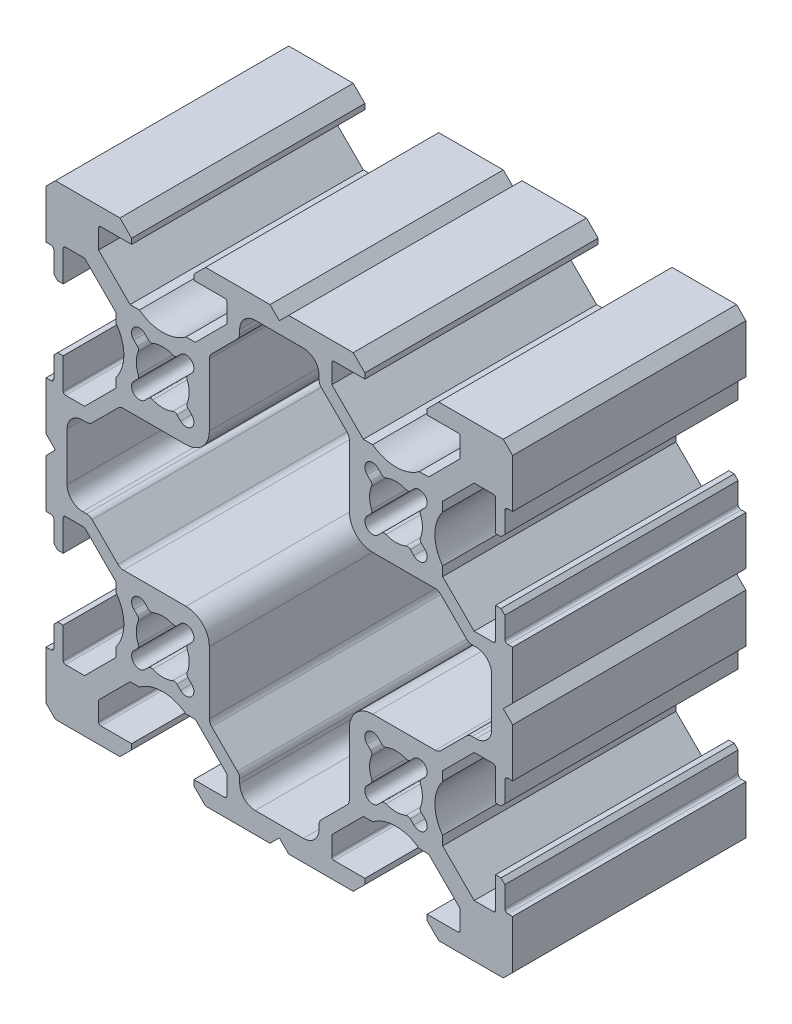
from build123d import *

# Parameters (mm, degrees)
EXTRUDE_1_DEPTH = 30


with BuildPart() as part:
    # Эскиз1 → Бобышка-Вытянуть1 (new body)
    with BuildSketch(Plane.XY):
        with BuildLine():
            Line((26.437609342, 19), (27.137609342, 19))
            Line((27.137609342, 19), (27.637609342, 19.5))
            Line((27.637609342, 19.5), (27.637609342, 22.15))
            ThreePointArc((27.637609342, 22.15), (27.75476663, 22.432842712), (28.037609342, 22.55))
            Line((28.037609342, 22.55), (28.637609342, 22.55))
            Line((28.637609342, 22.55), (28.637609342, 28.8))
            Line((28.637609342, 28.8), (27.437609342, 30))
            Line((27.437609342, 30), (19.137609342, 30))
            Line((19.137609342, 30), (17.637609342, 28.5))
            Line((17.637609342, 28.5), (17.637609342, 27.8))
            Line((17.637609342, 27.8), (21.587609342, 27.8))
            ThreePointArc((21.587609342, 27.8), (21.799741377, 27.712132034), (21.887609342, 27.5))
            Line((21.887609342, 27.5), (21.887609342, 25.05312252))
            Line((21.887609342, 25.05312252), (17.834486822, 21))
            Line((17.834486822, 21), (16.637609342, 21))
            ThreePointArc((16.637609342, 21), (13.637609342, 20), (10.637609342, 21))
            Line((10.637609342, 21), (9.440731863, 21))
            Line((9.440731863, 21), (5.387609342, 25.05312252))
            Line((5.387609342, 25.05312252), (5.387609342, 27.5))
            ThreePointArc((5.387609342, 27.5), (5.475477308, 27.712132034), (5.687609342, 27.8))
            Line((5.687609342, 27.8), (9.637609342, 27.8))
            Line((9.637609342, 27.8), (9.637609342, 28.5))
            Line((9.637609342, 28.5), (8.137609342, 30))
            Line((8.137609342, 30), (-0.162390658, 30))
            Line((-0.162390658, 30), (-1.362390658, 28.8))
            Line((-1.362390658, 28.8), (-2.562390658, 30))
            Line((-2.562390658, 30), (-10.862390658, 30))
            Line((-10.862390658, 30), (-12.362390658, 28.5))
            Line((-12.362390658, 28.5), (-12.362390658, 27.8))
            Line((-12.362390658, 27.8), (-8.412390658, 27.8))
            ThreePointArc((-8.412390658, 27.8), (-8.200258623, 27.712132034), (-8.112390658, 27.5))
            Line((-8.112390658, 27.5), (-8.112390658, 25.05312252))
            Line((-8.112390658, 25.05312252), (-12.165513178, 21))
            Line((-12.165513178, 21), (-13.362390658, 21))
            ThreePointArc((-13.362390658, 21), (-16.362390658, 20), (-19.362390658, 21))
            Line((-19.362390658, 21), (-20.559268137, 21))
            Line((-20.559268137, 21), (-24.612390658, 25.05312252))
            Line((-24.612390658, 25.05312252), (-24.612390658, 27.5))
            ThreePointArc((-24.612390658, 27.5), (-24.524522692, 27.712132034), (-24.312390658, 27.8))
            Line((-24.312390658, 27.8), (-20.362390658, 27.8))
            Line((-20.362390658, 27.8), (-20.362390658, 28.5))
            Line((-20.362390658, 28.5), (-21.862390658, 30))
            Line((-21.862390658, 30), (-30.162390658, 30))
            Line((-30.162390658, 30), (-31.362390658, 28.8))
            Line((-31.362390658, 28.8), (-31.362390658, 22.55))
            Line((-31.362390658, 22.55), (-30.762390658, 22.55))
            ThreePointArc((-30.762390658, 22.55), (-30.479547945, 22.432842712), (-30.362390658, 22.15))
            Line((-30.362390658, 22.15), (-30.362390658, 19.5))
            Line((-30.362390658, 19.5), (-29.862390658, 19))
            Line((-29.862390658, 19), (-29.162390658, 19))
            Line((-29.162390658, 19), (-29.162390658, 22.95))
            ThreePointArc((-29.162390658, 22.95), (-29.074522692, 23.162132034), (-28.862390658, 23.25))
            Line((-28.862390658, 23.25), (-26.415513178, 23.25))
            Line((-26.415513178, 23.25), (-22.362390658, 19.19687748))
            Line((-22.362390658, 19.19687748), (-22.362390658, 18))
            ThreePointArc((-22.362390658, 18), (-21.362390658, 15), (-22.362390658, 12))
            Line((-22.362390658, 12), (-22.362390658, 10.80312252))
            Line((-22.362390658, 10.80312252), (-26.415513178, 6.75))
            Line((-26.415513178, 6.75), (-28.862390658, 6.75))
            ThreePointArc((-28.862390658, 6.75), (-29.074522692, 6.837867966), (-29.162390658, 7.05))
            Line((-29.162390658, 7.05), (-29.162390658, 11))
            Line((-29.162390658, 11), (-29.862390658, 11))
            Line((-29.862390658, 11), (-30.362390658, 10.5))
            Line((-30.362390658, 10.5), (-30.362390658, 7.85))
            ThreePointArc((-30.362390658, 7.85), (-30.479547945, 7.567157288), (-30.762390658, 7.45))
            Line((-30.762390658, 7.45), (-31.362390658, 7.45))
            Line((-31.362390658, 7.45), (-31.362390658, 1.2))
            Line((-31.362390658, 1.2), (-30.162390658, 0))
            Line((-30.162390658, 0), (-31.362390658, -1.2))
            Line((-31.362390658, -1.2), (-31.362390658, -7.45))
            Line((-31.362390658, -7.45), (-30.762390658, -7.45))
            ThreePointArc((-30.762390658, -7.45), (-30.479547945, -7.567157288), (-30.362390658, -7.85))
            Line((-30.362390658, -7.85), (-30.362390658, -10.5))
            Line((-30.362390658, -10.5), (-29.862390658, -11))
            Line((-29.862390658, -11), (-29.162390658, -11))
            Line((-29.162390658, -11), (-29.162390658, -7.05))
            ThreePointArc((-29.162390658, -7.05), (-29.074522692, -6.837867966), (-28.862390658, -6.75))
            Line((-28.862390658, -6.75), (-26.415513178, -6.75))
            Line((-26.415513178, -6.75), (-22.362390658, -10.80312252))
            Line((-22.362390658, -10.80312252), (-22.362390658, -12))
            ThreePointArc((-22.362390658, -12), (-21.362390658, -15), (-22.362390658, -18))
            Line((-22.362390658, -18), (-22.362390658, -19.19687748))
            Line((-22.362390658, -19.19687748), (-26.415513178, -23.25))
            Line((-26.415513178, -23.25), (-28.862390658, -23.25))
            ThreePointArc((-28.862390658, -23.25), (-29.074522692, -23.162132034), (-29.162390658, -22.95))
            Line((-29.162390658, -22.95), (-29.162390658, -19))
            Line((-29.162390658, -19), (-29.862390658, -19))
            Line((-29.862390658, -19), (-30.362390658, -19.5))
            Line((-30.362390658, -19.5), (-30.362390658, -22.15))
            ThreePointArc((-30.362390658, -22.15), (-30.479547945, -22.432842712), (-30.762390658, -22.55))
            Line((-30.762390658, -22.55), (-31.362390658, -22.55))
            Line((-31.362390658, -22.55), (-31.362390658, -28.8))
            Line((-31.362390658, -28.8), (-30.162390658, -30))
            Line((-30.162390658, -30), (-21.862390658, -30))
            Line((-21.862390658, -30), (-20.362390658, -28.5))
            Line((-20.362390658, -28.5), (-20.362390658, -27.8))
            Line((-20.362390658, -27.8), (-24.312390658, -27.8))
            ThreePointArc((-24.312390658, -27.8), (-24.524522692, -27.712132034), (-24.612390658, -27.5))
            Line((-24.612390658, -27.5), (-24.612390658, -25.05312252))
            Line((-24.612390658, -25.05312252), (-20.559268137, -21))
            Line((-20.559268137, -21), (-19.362390658, -21))
            ThreePointArc((-19.362390658, -21), (-16.362390658, -20), (-13.362390658, -21))
            Line((-13.362390658, -21), (-12.165513178, -21))
            Line((-12.165513178, -21), (-8.112390658, -25.05312252))
            Line((-8.112390658, -25.05312252), (-8.112390658, -27.5))
            ThreePointArc((-8.112390658, -27.5), (-8.200258623, -27.712132034), (-8.412390658, -27.8))
            Line((-8.412390658, -27.8), (-12.362390658, -27.8))
            Line((-12.362390658, -27.8), (-12.362390658, -28.5))
            Line((-12.362390658, -28.5), (-10.862390658, -30))
            Line((-10.862390658, -30), (-2.562390658, -30))
            Line((-2.562390658, -30), (-1.362390658, -28.8))
            Line((-1.362390658, -28.8), (-0.162390658, -30))
            Line((-0.162390658, -30), (8.137609342, -30))
            Line((8.137609342, -30), (9.637609342, -28.5))
            Line((9.637609342, -28.5), (9.637609342, -27.8))
            Line((9.637609342, -27.8), (5.687609342, -27.8))
            ThreePointArc((5.687609342, -27.8), (5.475477308, -27.712132034), (5.387609342, -27.5))
            Line((5.387609342, -27.5), (5.387609342, -25.05312252))
            Line((5.387609342, -25.05312252), (9.440731863, -21))
            Line((9.440731863, -21), (10.637609342, -21))
            ThreePointArc((10.637609342, -21), (13.637609342, -20), (16.637609342, -21))
            Line((16.637609342, -21), (17.834486822, -21))
            Line((17.834486822, -21), (21.887609342, -25.05312252))
            Line((21.887609342, -25.05312252), (21.887609342, -27.5))
            ThreePointArc((21.887609342, -27.5), (21.799741377, -27.712132034), (21.587609342, -27.8))
            Line((21.587609342, -27.8), (17.637609342, -27.8))
            Line((17.637609342, -27.8), (17.637609342, -28.5))
            Line((17.637609342, -28.5), (19.137609342, -30))
            Line((19.137609342, -30), (27.437609342, -30))
            Line((27.437609342, -30), (28.637609342, -28.8))
            Line((28.637609342, -28.8), (28.637609342, -22.55))
            Line((28.637609342, -22.55), (28.037609342, -22.55))
            ThreePointArc((28.037609342, -22.55), (27.75476663, -22.432842712), (27.637609342, -22.15))
            Line((27.637609342, -22.15), (27.637609342, -19.5))
            Line((27.637609342, -19.5), (27.137609342, -19))
            Line((27.137609342, -19), (26.437609342, -19))
            Line((26.437609342, -19), (26.437609342, -22.95))
            ThreePointArc((26.437609342, -22.95), (26.349741377, -23.162132034), (26.137609342, -23.25))
            Line((26.137609342, -23.25), (23.690731863, -23.25))
            Line((23.690731863, -23.25), (19.637609342, -19.19687748))
            Line((19.637609342, -19.19687748), (19.637609342, -18))
            ThreePointArc((19.637609342, -18), (18.637609342, -15), (19.637609342, -12))
            Line((19.637609342, -12), (19.637609342, -10.80312252))
            Line((19.637609342, -10.80312252), (23.690731863, -6.75))
            Line((23.690731863, -6.75), (26.137609342, -6.75))
            ThreePointArc((26.137609342, -6.75), (26.349741377, -6.837867966), (26.437609342, -7.05))
            Line((26.437609342, -7.05), (26.437609342, -11))
            Line((26.437609342, -11), (27.137609342, -11))
            Line((27.137609342, -11), (27.637609342, -10.5))
            Line((27.637609342, -10.5), (27.637609342, -7.85))
            ThreePointArc((27.637609342, -7.85), (27.75476663, -7.567157288), (28.037609342, -7.45))
            Line((28.037609342, -7.45), (28.637609342, -7.45))
            Line((28.637609342, -7.45), (28.637609342, -1.2))
            Line((28.637609342, -1.2), (27.437609342, 0))
            Line((27.437609342, 0), (28.637609342, 1.2))
            Line((28.637609342, 1.2), (28.637609342, 7.45))
            Line((28.637609342, 7.45), (28.037609342, 7.45))
            ThreePointArc((28.037609342, 7.45), (27.75476663, 7.567157288), (27.637609342, 7.85))
            Line((27.637609342, 7.85), (27.637609342, 10.5))
            Line((27.637609342, 10.5), (27.137609342, 11))
            Line((27.137609342, 11), (26.437609342, 11))
            Line((26.437609342, 11), (26.437609342, 7.05))
            ThreePointArc((26.437609342, 7.05), (26.349741377, 6.837867966), (26.137609342, 6.75))
            Line((26.137609342, 6.75), (23.690731863, 6.75))
            Line((23.690731863, 6.75), (19.637609342, 10.80312252))
            Line((19.637609342, 10.80312252), (19.637609342, 12))
            ThreePointArc((19.637609342, 12), (18.637609342, 15), (19.637609342, 18))
            Line((19.637609342, 18), (19.637609342, 19.19687748))
            Line((19.637609342, 19.19687748), (23.690731863, 23.25))
            Line((23.690731863, 23.25), (26.137609342, 23.25))
            ThreePointArc((26.137609342, 23.25), (26.349741377, 23.162132034), (26.437609342, 22.95))
            Line((26.437609342, 22.95), (26.437609342, 19))
        make_face()
        with BuildLine():
            Line((-19.615081851, -16.838477631), (-20.074701259, -17.298097039))
            ThreePointArc((-20.074701259, -17.298097039), (-20.074701259, -18.712310601), (-18.660487697, -18.712310601))
            Line((-18.660487697, -18.712310601), (-18.200868289, -18.252691193))
            ThreePointArc((-18.200868289, -18.252691193), (-17.945372966, -18.115954246), (-17.656939996, -18.143905535))
            ThreePointArc((-17.656939996, -18.143905535), (-16.362390658, -18.4), (-15.06784132, -18.143905535))
            ThreePointArc((-15.06784132, -18.143905535), (-14.77940835, -18.115954246), (-14.523913027, -18.252691193))
            Line((-14.523913027, -18.252691193), (-14.064293619, -18.712310601))
            ThreePointArc((-14.064293619, -18.712310601), (-12.650080057, -18.712310601), (-12.650080057, -17.298097039))
            Line((-12.650080057, -17.298097039), (-13.109699464, -16.838477631))
            ThreePointArc((-13.109699464, -16.838477631), (-13.246436412, -16.582982308), (-13.218485123, -16.294549338))
            ThreePointArc((-13.218485123, -16.294549338), (-12.962390658, -15), (-13.218485123, -13.705450662))
            ThreePointArc((-13.218485123, -13.705450662), (-13.246436412, -13.417017692), (-13.109699464, -13.161522369))
            Line((-13.109699464, -13.161522369), (-12.650080057, -12.701902961))
            ThreePointArc((-12.650080057, -12.701902961), (-12.650080057, -11.287689399), (-14.064293619, -11.287689399))
            Line((-14.064293619, -11.287689399), (-14.523913027, -11.747308806))
            ThreePointArc((-14.523913027, -11.747308806), (-14.77940835, -11.884045754), (-15.06784132, -11.856094465))
            ThreePointArc((-15.06784132, -11.856094465), (-16.362390658, -11.6), (-17.656939996, -11.856094465))
            ThreePointArc((-17.656939996, -11.856094465), (-17.945372966, -11.884045754), (-18.200868289, -11.747308807))
            Line((-18.200868289, -11.747308807), (-18.660487697, -11.287689399))
            ThreePointArc((-18.660487697, -11.287689399), (-20.074701259, -11.287689399), (-20.074701259, -12.701902961))
            Line((-20.074701259, -12.701902961), (-19.615081851, -13.161522369))
            ThreePointArc((-19.615081851, -13.161522369), (-19.478344904, -13.417017692), (-19.506296193, -13.705450662))
            ThreePointArc((-19.506296193, -13.705450662), (-19.762390658, -15), (-19.506296193, -16.294549338))
            ThreePointArc((-19.506296193, -16.294549338), (-19.478344904, -16.582982308), (-19.615081851, -16.838477631))
        make_face(mode=Mode.SUBTRACT)
        with BuildLine():
            Line((9.925298741, -12.701902961), (10.384918149, -13.161522369))
            ThreePointArc((10.384918149, -13.161522369), (10.521655096, -13.417017692), (10.493703807, -13.705450662))
            ThreePointArc((10.493703807, -13.705450662), (10.237609342, -15), (10.493703807, -16.294549338))
            ThreePointArc((10.493703807, -16.294549338), (10.521655096, -16.582982308), (10.384918149, -16.838477631))
            Line((10.384918149, -16.838477631), (9.925298741, -17.298097039))
            ThreePointArc((9.925298741, -17.298097039), (9.925298741, -18.712310601), (11.339512303, -18.712310601))
            Line((11.339512303, -18.712310601), (11.799131711, -18.252691193))
            ThreePointArc((11.799131711, -18.252691193), (12.054627034, -18.115954246), (12.343060004, -18.143905535))
            ThreePointArc((12.343060004, -18.143905535), (13.637609342, -18.4), (14.93215868, -18.143905535))
            ThreePointArc((14.93215868, -18.143905535), (15.22059165, -18.115954246), (15.476086973, -18.252691193))
            Line((15.476086973, -18.252691193), (15.935706381, -18.712310601))
            ThreePointArc((15.935706381, -18.712310601), (17.349919943, -18.712310601), (17.349919943, -17.298097039))
            Line((17.349919943, -17.298097039), (16.890300535, -16.838477631))
            ThreePointArc((16.890300535, -16.838477631), (16.753563588, -16.582982308), (16.781514877, -16.294549338))
            ThreePointArc((16.781514877, -16.294549338), (17.037609342, -15), (16.781514877, -13.705450662))
            ThreePointArc((16.781514877, -13.705450662), (16.753563588, -13.417017692), (16.890300535, -13.161522369))
            Line((16.890300535, -13.161522369), (17.349919943, -12.701902961))
            ThreePointArc((17.349919943, -12.701902961), (17.349919943, -11.287689399), (15.935706381, -11.287689399))
            Line((15.935706381, -11.287689399), (15.476086973, -11.747308807))
            ThreePointArc((15.476086973, -11.747308807), (15.22059165, -11.884045754), (14.93215868, -11.856094465))
            ThreePointArc((14.93215868, -11.856094465), (13.637609342, -11.6), (12.343060004, -11.856094465))
            ThreePointArc((12.343060004, -11.856094465), (12.054627034, -11.884045754), (11.799131711, -11.747308807))
            Line((11.799131711, -11.747308807), (11.339512303, -11.287689399))
            ThreePointArc((11.339512303, -11.287689399), (9.925298741, -11.287689399), (9.925298741, -12.701902961))
        make_face(mode=Mode.SUBTRACT)
        with BuildLine():
            Line((10.384918149, 13.161522369), (9.925298741, 12.701902961))
            ThreePointArc((9.925298741, 12.701902961), (9.925298741, 11.287689399), (11.339512303, 11.287689399))
            Line((11.339512303, 11.287689399), (11.799131711, 11.747308807))
            ThreePointArc((11.799131711, 11.747308807), (12.054627034, 11.884045754), (12.343060004, 11.856094465))
            ThreePointArc((12.343060004, 11.856094465), (13.637609342, 11.6), (14.93215868, 11.856094465))
            ThreePointArc((14.93215868, 11.856094465), (15.22059165, 11.884045754), (15.476086973, 11.747308807))
            Line((15.476086973, 11.747308807), (15.935706381, 11.287689399))
            ThreePointArc((15.935706381, 11.287689399), (17.349919943, 11.287689399), (17.349919943, 12.701902961))
            Line((17.349919943, 12.701902961), (16.890300536, 13.161522369))
            ThreePointArc((16.890300536, 13.161522369), (16.753563588, 13.417017692), (16.781514877, 13.705450662))
            ThreePointArc((16.781514877, 13.705450662), (17.037609342, 15), (16.781514877, 16.294549338))
            ThreePointArc((16.781514877, 16.294549338), (16.753563588, 16.582982308), (16.890300536, 16.838477631))
            Line((16.890300536, 16.838477631), (17.349919943, 17.298097039))
            ThreePointArc((17.349919943, 17.298097039), (17.349919943, 18.712310601), (15.935706381, 18.712310601))
            Line((15.935706381, 18.712310601), (15.476086973, 18.252691194))
            ThreePointArc((15.476086973, 18.252691194), (15.22059165, 18.115954246), (14.93215868, 18.143905535))
            ThreePointArc((14.93215868, 18.143905535), (13.637609342, 18.4), (12.343060004, 18.143905535))
            ThreePointArc((12.343060004, 18.143905535), (12.054627034, 18.115954246), (11.799131711, 18.252691193))
            Line((11.799131711, 18.252691193), (11.339512303, 18.712310601))
            ThreePointArc((11.339512303, 18.712310601), (9.925298741, 18.712310601), (9.925298741, 17.298097039))
            Line((9.925298741, 17.298097039), (10.384918149, 16.838477631))
            ThreePointArc((10.384918149, 16.838477631), (10.521655096, 16.582982308), (10.493703807, 16.294549338))
            ThreePointArc((10.493703807, 16.294549338), (10.237609342, 15), (10.493703807, 13.705450662))
            ThreePointArc((10.493703807, 13.705450662), (10.521655096, 13.417017692), (10.384918149, 13.161522369))
        make_face(mode=Mode.SUBTRACT)
        with BuildLine():
            Line((-18.200868289, 18.252691193), (-18.660487697, 18.712310601))
            ThreePointArc((-18.660487697, 18.712310601), (-20.074701259, 18.712310601), (-20.074701259, 17.298097039))
            Line((-20.074701259, 17.298097039), (-19.615081851, 16.838477631))
            ThreePointArc((-19.615081851, 16.838477631), (-19.478344904, 16.582982308), (-19.506296193, 16.294549338))
            ThreePointArc((-19.506296193, 16.294549338), (-19.762390658, 15), (-19.506296193, 13.705450662))
            ThreePointArc((-19.506296193, 13.705450662), (-19.478344904, 13.417017692), (-19.615081851, 13.161522369))
            Line((-19.615081851, 13.161522369), (-20.074701259, 12.701902961))
            ThreePointArc((-20.074701259, 12.701902961), (-20.074701259, 11.287689399), (-18.660487697, 11.287689399))
            Line((-18.660487697, 11.287689399), (-18.200868289, 11.747308807))
            ThreePointArc((-18.200868289, 11.747308807), (-17.945372966, 11.884045754), (-17.656939996, 11.856094465))
            ThreePointArc((-17.656939996, 11.856094465), (-16.362390658, 11.6), (-15.06784132, 11.856094465))
            ThreePointArc((-15.06784132, 11.856094465), (-14.77940835, 11.884045754), (-14.523913027, 11.747308807))
            Line((-14.523913027, 11.747308807), (-14.064293619, 11.287689399))
            ThreePointArc((-14.064293619, 11.287689399), (-12.650080057, 11.287689399), (-12.650080057, 12.701902961))
            Line((-12.650080057, 12.701902961), (-13.109699465, 13.161522369))
            ThreePointArc((-13.109699465, 13.161522369), (-13.246436412, 13.417017692), (-13.218485123, 13.705450662))
            ThreePointArc((-13.218485123, 13.705450662), (-12.962390658, 15), (-13.218485123, 16.294549338))
            ThreePointArc((-13.218485123, 16.294549338), (-13.246436412, 16.582982308), (-13.109699464, 16.838477631))
            Line((-13.109699464, 16.838477631), (-12.650080057, 17.298097039))
            ThreePointArc((-12.650080057, 17.298097039), (-12.650080057, 18.712310601), (-14.064293619, 18.712310601))
            Line((-14.064293619, 18.712310601), (-14.523913027, 18.252691193))
            ThreePointArc((-14.523913027, 18.252691193), (-14.77940835, 18.115954246), (-15.06784132, 18.143905535))
            ThreePointArc((-15.06784132, 18.143905535), (-16.362390658, 18.4), (-17.656939996, 18.143905535))
            ThreePointArc((-17.656939996, 18.143905535), (-17.945372966, 18.115954246), (-18.200868289, 18.252691193))
        make_face(mode=Mode.SUBTRACT)
        with BuildLine():
            Line((7.344716123, 20.762563361), (4.030502561, 24.076776924))
            ThreePointArc((4.030502561, 24.076776924), (3.81372981, 24.401200273), (3.737609342, 24.783883705))
            Line((3.737609342, 24.783883705), (3.737609342, 25.3))
            ThreePointArc((3.737609342, 25.3), (3.151822905, 26.714213562), (1.737609342, 27.3))
            Line((1.737609342, 27.3), (-4.462390658, 27.3))
            ThreePointArc((-4.462390658, 27.3), (-5.87660422, 26.714213562), (-6.462390658, 25.3))
            Line((-6.462390658, 25.3), (-6.462390658, 24.783883705))
            ThreePointArc((-6.462390658, 24.783883705), (-6.538511125, 24.401200273), (-6.755283877, 24.076776924))
            Line((-6.755283877, 24.076776924), (-10.069497439, 20.762563361))
            ThreePointArc((-10.069497439, 20.762563361), (-10.286084063, 20.438589056), (-10.362390185, 20.05642876))
            Line((-10.362390185, 20.05642876), (-10.370217712, 12.004909098))
            ThreePointArc((-10.370217712, 12.004909098), (-11.248895951, 9.886505293), (-13.367299755, 9.007827054))
            Line((-13.367299755, 9.007827054), (-21.418819418, 8.999999527))
            ThreePointArc((-21.418819418, 8.999999527), (-21.800979714, 8.923693405), (-22.124954019, 8.707106781))
            Line((-22.124954019, 8.707106781), (-25.439167582, 5.392893219))
            ThreePointArc((-25.439167582, 5.392893219), (-25.76359093, 5.176120467), (-26.146274363, 5.1))
            Line((-26.146274363, 5.1), (-26.662390658, 5.1))
            ThreePointArc((-26.662390658, 5.1), (-28.07660422, 4.514213562), (-28.662390658, 3.1))
            Line((-28.662390658, 3.1), (-28.662390658, -3.1))
            ThreePointArc((-28.662390658, -3.1), (-28.07660422, -4.514213562), (-26.662390658, -5.1))
            Line((-26.662390658, -5.1), (-26.146274363, -5.1))
            ThreePointArc((-26.146274363, -5.1), (-25.76359093, -5.176120467), (-25.439167582, -5.392893219))
            Line((-25.439167582, -5.392893219), (-22.124954019, -8.707106781))
            ThreePointArc((-22.124954019, -8.707106781), (-21.800979714, -8.923693405), (-21.418819418, -8.999999527))
            Line((-21.418819418, -8.999999527), (-13.367299755, -9.007827054))
            ThreePointArc((-13.367299755, -9.007827054), (-11.248895951, -9.886505293), (-10.370217712, -12.004909098))
            Line((-10.370217712, -12.004909098), (-10.362390185, -20.05642876))
            ThreePointArc((-10.362390185, -20.05642876), (-10.286084063, -20.438589056), (-10.069497439, -20.762563361))
            Line((-10.069497439, -20.762563361), (-6.755283877, -24.076776924))
            ThreePointArc((-6.755283877, -24.076776924), (-6.538511125, -24.401200273), (-6.462390658, -24.783883705))
            Line((-6.462390658, -24.783883705), (-6.462390658, -25.3))
            ThreePointArc((-6.462390658, -25.3), (-5.87660422, -26.714213562), (-4.462390658, -27.3))
            Line((-4.462390658, -27.3), (1.737609342, -27.3))
            ThreePointArc((1.737609342, -27.3), (3.151822905, -26.714213562), (3.737609342, -25.3))
            Line((3.737609342, -25.3), (3.737609342, -24.783883705))
            ThreePointArc((3.737609342, -24.783883705), (3.81372981, -24.401200273), (4.030502561, -24.076776924))
            Line((4.030502561, -24.076776924), (7.344716123, -20.762563361))
            ThreePointArc((7.344716123, -20.762563361), (7.561302747, -20.438589056), (7.63760887, -20.05642876))
            Line((7.63760887, -20.05642876), (7.645436396, -12.004909098))
            ThreePointArc((7.645436396, -12.004909098), (8.524114635, -9.886505293), (10.64251844, -9.007827054))
            Line((10.64251844, -9.007827054), (18.694038102, -8.999999527))
            ThreePointArc((18.694038102, -8.999999527), (19.076198398, -8.923693405), (19.400172703, -8.707106781))
            Line((19.400172703, -8.707106781), (22.714386266, -5.392893219))
            ThreePointArc((22.714386266, -5.392893219), (23.038809615, -5.176120467), (23.421493047, -5.1))
            Line((23.421493047, -5.1), (23.937609342, -5.1))
            ThreePointArc((23.937609342, -5.1), (25.351822905, -4.514213562), (25.937609342, -3.1))
            Line((25.937609342, -3.1), (25.937609342, 3.1))
            ThreePointArc((25.937609342, 3.1), (25.351822905, 4.514213562), (23.937609342, 5.1))
            Line((23.937609342, 5.1), (23.421493047, 5.1))
            ThreePointArc((23.421493047, 5.1), (23.038809615, 5.176120467), (22.714386266, 5.392893219))
            Line((22.714386266, 5.392893219), (19.400172703, 8.707106781))
            ThreePointArc((19.400172703, 8.707106781), (19.076198398, 8.923693405), (18.694038102, 8.999999527))
            Line((18.694038102, 8.999999527), (10.64251844, 9.007827054))
            ThreePointArc((10.64251844, 9.007827054), (8.524114635, 9.886505293), (7.645436396, 12.004909098))
            Line((7.645436396, 12.004909098), (7.63760887, 20.05642876))
            ThreePointArc((7.63760887, 20.05642876), (7.561302747, 20.438589056), (7.344716123, 20.762563361))
        make_face(mode=Mode.SUBTRACT)
    extrude(amount=EXTRUDE_1_DEPTH)


solid = part.part
